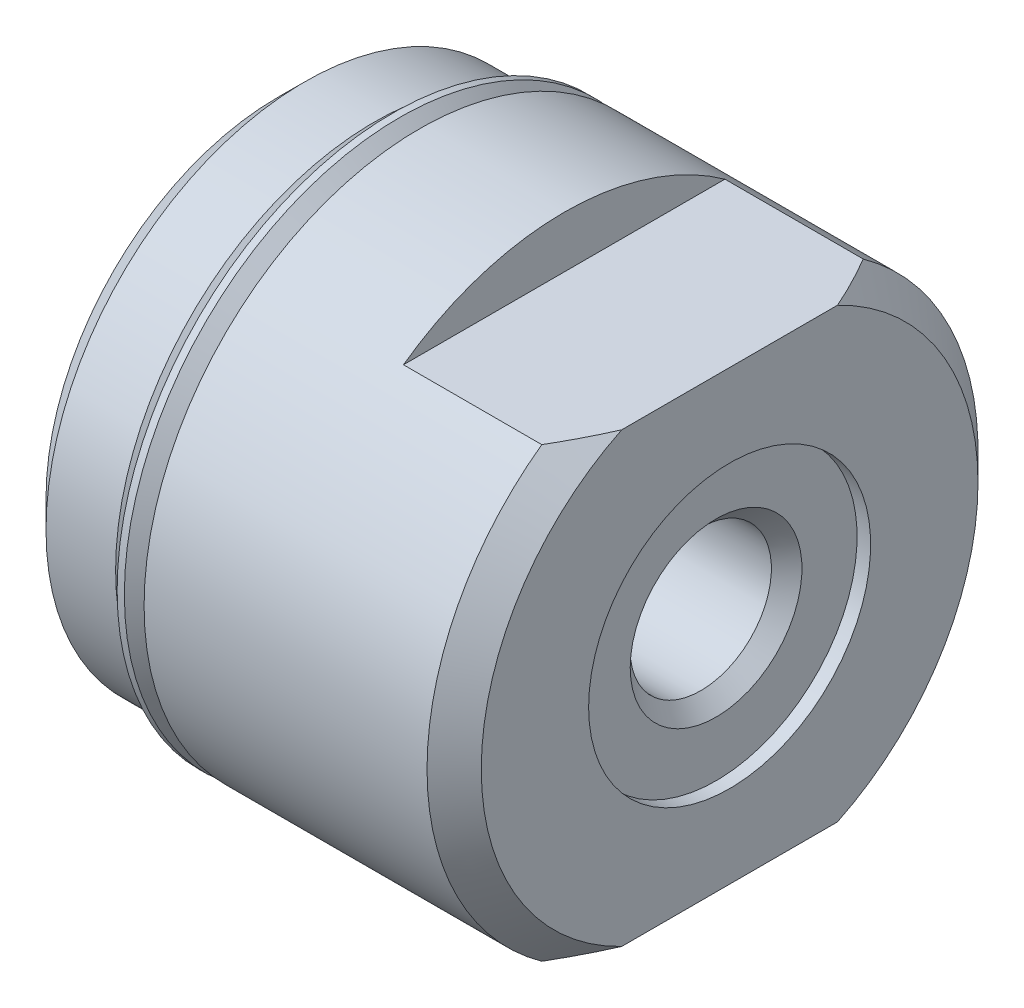
from build123d import *

# Parameters (mm, degrees)
SKETCH2_W          = 0.381
SKETCH2_H          = 3.9624
SKETCH4_W          = 61.9252
SKETCH4_H          = 30.9626
SKETCH4_W_2        = 30.9626
SKETCH4_H_2        = 12.573
CUT_EXTRUDE1_DEPTH = 4.6482


with BuildPart() as part:
    # Sketch1 → Revolve1 (revolve)
    with BuildSketch(Plane.XY):
        Polygon((0, 0), (0, 6.50875), (0.762, 7.27075), (2.7178, 7.27075), (3.3528, 6.63575), (3.9878, 6.63575), (3.9878, 7.74065), (11.938, 7.74065), (12.7, 6.97865), (12.7, 0), align=None)
    revolve(axis=Axis((12.7, 0, 0), (-1, 0, 0)))

    # Sketch2 → Cut-Revolve1 (revolve, cut)
    with BuildSketch(Plane.XY):
        with Locations((12.5095, 1.9812)):
            Rectangle(SKETCH2_W, SKETCH2_H)
    revolve(axis=Axis((12.7, 0, 0), (-1, 0, 0)), mode=Mode.SUBTRACT)

    # Sketch3 → Cut-Revolve2 (revolve, cut)
    with BuildSketch(Plane.XY):
        Polygon((0, 0), (0, 1.98374), (11.88974, 1.98374), (12.319, 2.413), (12.319, 0), align=None)
    revolve(axis=Axis((12.319, 0, 0), (-1, 0, 0)), mode=Mode.SUBTRACT)

    # Sketch4 → Cut-Extrude1 (cut)
    with BuildSketch(Plane(origin=(12.7, 0, 0), x_dir=(0, 0, -1), z_dir=(1, 0, 0))):
        Rectangle(SKETCH4_W, SKETCH4_H)
        Rectangle(SKETCH4_W_2, SKETCH4_H_2, mode=Mode.SUBTRACT)
    extrude(amount=-CUT_EXTRUDE1_DEPTH, mode=Mode.SUBTRACT)

    # Sketch5 → Revolve2 (revolve)
    with BuildSketch(Plane.XY):
        with BuildLine():
            Line((3.230093808, 7.74065), (3.230093808, 7.656481804))
            Line((3.230093808, 7.656481804), (3.870760245, 7.015815367))
            ThreePointArc((3.870760245, 7.015815367), (3.907957684, 6.926012806), (3.870760245, 6.836210245))
            Line((3.870760245, 6.836210245), (3.6703, 6.63575))
            Line((3.6703, 6.63575), (3.3528, 6.63575))
            Line((3.3528, 6.63575), (3.3528, 6.38175))
            Line((3.3528, 6.38175), (3.9878, 6.38175))
            Line((3.9878, 6.38175), (3.9878, 7.186143808))
            Line((3.9878, 7.186143808), (3.433293808, 7.74065))
            Line((3.433293808, 7.74065), (3.230093808, 7.74065))
        make_face()
    revolve(axis=Axis((3.9878, 0, 0), (-1, 0, 0)))


solid = part.part
